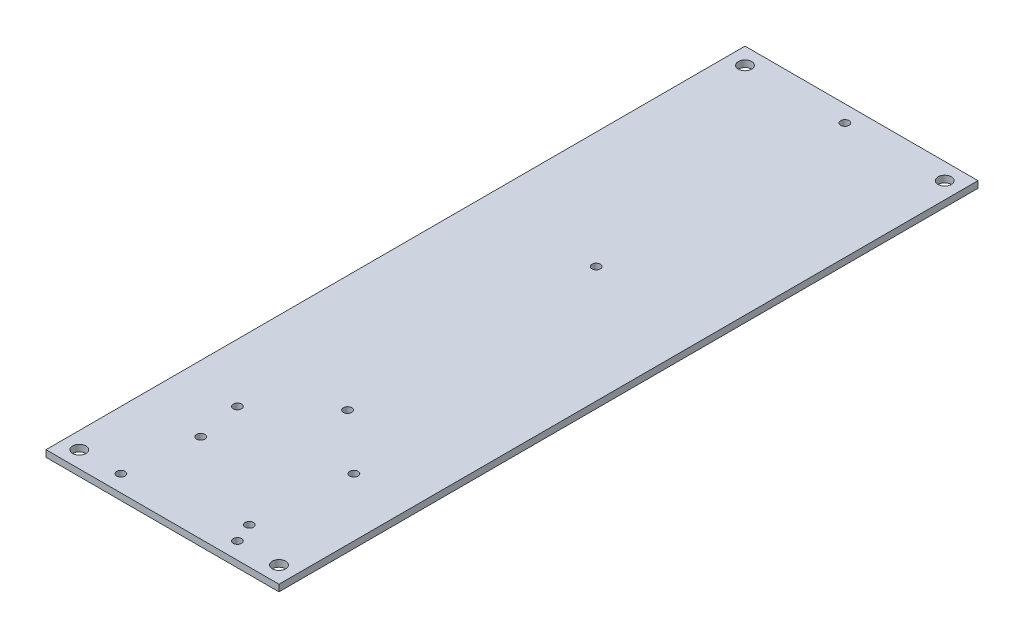
from build123d import *

# Parameters (mm, degrees)
SKETCH1_W               = 70
SKETCH1_H               = 210
BOSS_EXTRUDE1_DEPTH     = 2
SKETCH2_R               = 2
CUT_EXTRUDE1_DEPTH      = 3
TAP_DRILL_FOR_M3_TAP1_D = 2.5
TAP_DRILL_FOR_M3_TAP2_D = 2.5
TAP_DRILL_FOR_M3_TAP3_D = 2.5


with BuildPart() as part:
    # Sketch1 → Boss-Extrude1 (new body)
    with BuildSketch(Plane(origin=(0, 0, 0), x_dir=(1, 0, 0), z_dir=(0, 1, 0))):
        with Locations((35, 105)):
            Rectangle(SKETCH1_W, SKETCH1_H)
    extrude(amount=BOSS_EXTRUDE1_DEPTH)

    # Sketch2 → Cut-Extrude1 (cut, through all)
    with BuildSketch(Plane(origin=(0, 2, 0), x_dir=(1, 0, 0), z_dir=(0, 1, 0))):
        with Locations((5, 205)):
            Circle(SKETCH2_R)
        with Locations((65, 205)):
            Circle(SKETCH2_R)
        with Locations((65, 5)):
            Circle(SKETCH2_R)
        with Locations((5, 5)):
            Circle(SKETCH2_R)
    extrude(amount=-CUT_EXTRUDE1_DEPTH, mode=Mode.SUBTRACT)

    # Tap Drill for M3 Tap1 (through all)
    with Locations(Plane(origin=(0, 2, 0), x_dir=(1, 0, 0), z_dir=(0, 1, 0))):
        with Locations((35, 205), (35, 130.3), (35, 55.6)):
            Hole(TAP_DRILL_FOR_M3_TAP1_D / 2)

    # Tap Drill for M3 Tap2 (through all)
    with Locations(Plane(origin=(0, 2, 0), x_dir=(1, 0, 0), z_dir=(0, 1, 0))):
        with Locations((52.5, 5), (17.5, 5), (17.5, 40), (52.5, 40)):
            Hole(TAP_DRILL_FOR_M3_TAP2_D / 2)

    # Tap Drill for M3 Tap3 (through all)
    with Locations(Plane(origin=(0, 2, 0), x_dir=(1, 0, 0), z_dir=(0, 1, 0))):
        with Locations((19.9, 26.6), (50.1, 11)):
            Hole(TAP_DRILL_FOR_M3_TAP3_D / 2)


solid = part.part
